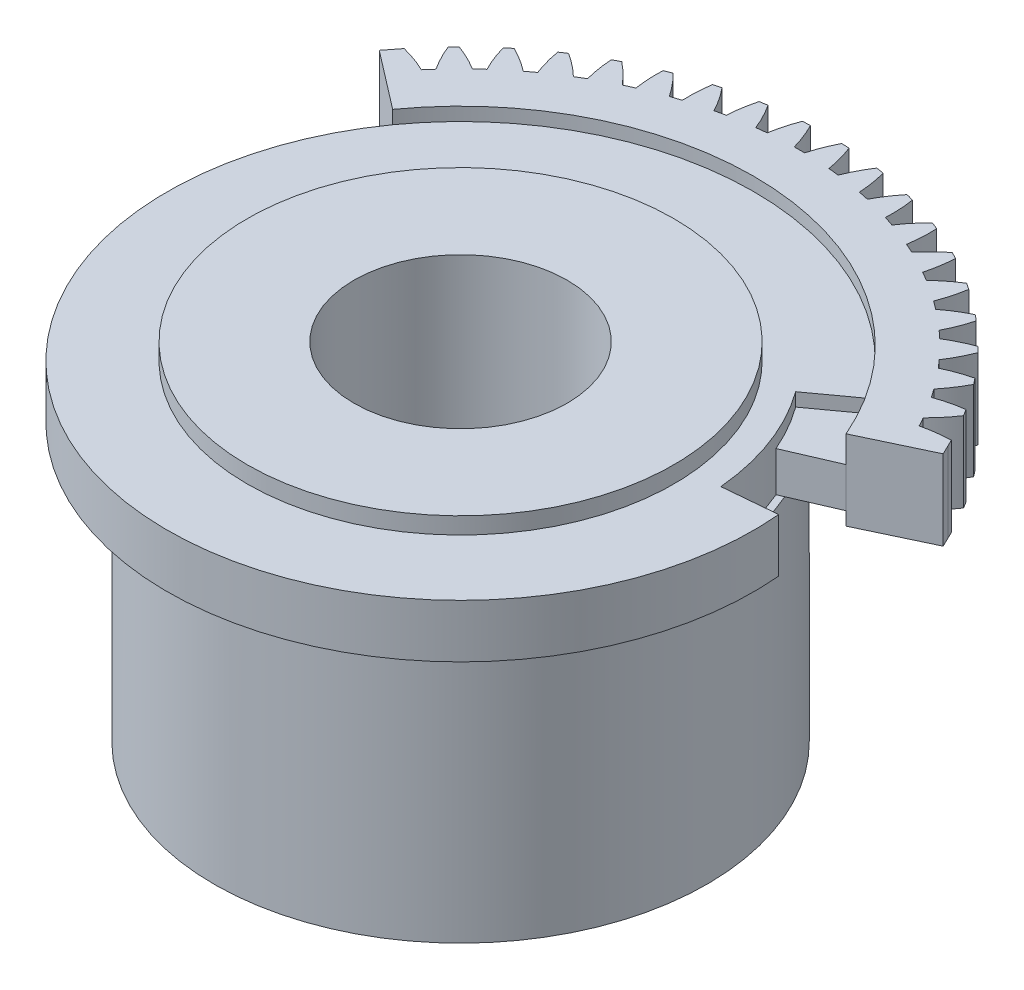
from build123d import *

# Parameters (mm, degrees)
BOSS_EXTRUDE1_DEPTH = 6
BOSS_EXTRUDE2_START = 1
SKETCH1_3_R         = 16
BOSS_EXTRUDE2_DEPTH = 4
CUT_EXTRUDE2_START  = 5
CUT_EXTRUDE2_DEPTH  = 1
SKETCH1_5_R         = 16
SKETCH1_5_R_2       = 8
BOSS_EXTRUDE3_DEPTH = 6.25
SKETCH2_R           = 18.5
BOSS_EXTRUDE4_DEPTH = 20.75
CUT_EXTRUDE3_START  = 6.25
SKETCH1_6_R         = 8
CUT_EXTRUDE3_DEPTH  = 13
SKETCH3_R           = 5
CUT_EXTRUDE4_DEPTH  = 11


with BuildPart() as part:
    # Sketch1 → Boss-Extrude1 (new body)
    with BuildSketch(Plane(origin=(0, 0, 0), x_dir=(1, 0, 0), z_dir=(0, 1, 0))):
        with BuildLine():
            ThreePointArc((17.805731394, 12.921142733), (19.115621979, 10.890041155), (20.194814379, 8.727512373))
            Line((20.194814379, 8.727512373), (25.139742278, 11.067703815))
            Line((25.139742278, 11.067703815), (24.811761788, 11.742187913))
            ThreePointArc((24.811761788, 11.742187913), (24.686117973, 12.004085947), (24.557709816, 12.264639767))
            ThreePointArc((24.557709816, 12.264639767), (23.484144419, 12.175944584), (22.425086919, 11.978950399))
            ThreePointArc((22.425086919, 11.978950399), (22.239976661, 12.319221327), (22.049703631, 12.656632481))
            ThreePointArc((22.049703631, 12.656632481), (22.778448625, 13.44994215), (23.423080118, 14.312994718))
            ThreePointArc((23.423080118, 14.312994718), (23.270310046, 14.560053928), (23.114934172, 14.805482708))
            ThreePointArc((23.114934172, 14.805482708), (22.056878458, 14.603176993), (21.02475993, 14.294727906))
            ThreePointArc((21.02475993, 14.294727906), (20.804529775, 14.613395117), (20.579470072, 14.928669986))
            ThreePointArc((20.579470072, 14.928669986), (21.21976293, 15.794946243), (21.769005591, 16.721629574))
            ThreePointArc((21.769005591, 16.721629574), (21.590840207, 16.95105068), (21.410257088, 17.178573614))
            ThreePointArc((21.410257088, 17.178573614), (20.379699251, 16.864949571), (19.386214008, 16.448540434))
            ThreePointArc((19.386214008, 16.448540434), (19.133359253, 16.741993301), (18.876062894, 17.031559695))
            ThreePointArc((18.876062894, 17.031559695), (19.420648841, 17.960987283), (19.868279532, 18.940801685))
            ThreePointArc((19.868279532, 18.940801685), (19.666737521, 19.149985255), (19.462993236, 19.357024417))
            ThreePointArc((19.462993236, 19.357024417), (18.471609908, 18.935635532), (17.528014536, 18.415984427))
            ThreePointArc((17.528014536, 18.415984427), (17.245400125, 18.680898012), (16.95878238, 18.941475027))
            ThreePointArc((16.95878238, 18.941475027), (17.401491042, 19.923523161), (17.742437927, 20.945366944))
            ThreePointArc((17.742437927, 20.945366944), (17.519802841, 21.131942845), (17.295205894, 21.316152399))
            ThreePointArc((17.295205894, 21.316152399), (16.354229843, 20.791773177), (15.471215656, 20.174767957))
            ThreePointArc((15.471215656, 20.174767957), (15.162043723, 20.408140683), (14.849352086, 20.636775878))
            ThreePointArc((14.849352086, 20.636775878), (15.185167395, 21.66031756), (15.41556741, 22.712612827))
            ThreePointArc((15.41556741, 22.712612827), (15.174361794, 22.874467079), (14.931456958, 23.033759856))
            ThreePointArc((14.931456958, 23.033759856), (14.05154982, 22.412331723), (13.23912172, 21.704963305))
            ThreePointArc((13.23912172, 21.704963305), (12.906895308, 21.904150965), (12.571672699, 22.098253812))
            ThreePointArc((12.571672699, 22.098253812), (12.796789734, 23.151691906), (12.914032356, 24.222515731))
            ThreePointArc((12.914032356, 24.222515731), (12.656989165, 24.35781446), (12.398528649, 24.49038561))
            ThreePointArc((12.398528649, 24.49038561), (11.589660123, 23.778949595), (10.857023245, 22.989232746))
            ThreePointArc((10.857023245, 22.989232746), (10.505506611, 23.151978465), (10.151551237, 23.309349701))
            ThreePointArc((10.151551237, 23.309349701), (10.263419333, 24.380748332), (10.266176154, 25.457967852))
            ThreePointArc((10.266176154, 25.457967852), (9.996207791, 25.565178071), (9.725120055, 25.66952551))
            ThreePointArc((9.725120055, 25.66952551), (8.996454945, 24.876142467), (8.351910358, 24.013024994))
            ThreePointArc((8.351910358, 24.013024994), (7.985086326, 24.137484798), (7.616408643, 24.256341344))
            ThreePointArc((7.616408643, 24.256341344), (7.613760289, 25.333561137), (7.502000074, 26.404971026))
            ThreePointArc((7.502000074, 26.404971026), (7.222165388, 26.482877999), (6.941521966, 26.557819428))
            ThreePointArc((6.941521966, 26.557819428), (6.301316338, 25.691478704), (5.752166989, 24.764740074))
            ThreePointArc((5.752166989, 24.764740074), (5.374191823, 24.849503783), (4.994969096, 24.928498947))
            ThreePointArc((4.994969096, 24.928498947), (4.877834298, 25.999334571), (4.652823336, 27.052795327))
            ThreePointArc((4.652823336, 27.052795327), (4.366292966, 27.100516337), (4.079273659, 27.145202641))
            ThreePointArc((4.079273659, 27.145202641), (3.5347813, 26.215720222), (3.087249271, 25.235860753))
            ThreePointArc((3.087249271, 25.235860753), (2.702405579, 25.279967961), (2.316934553, 25.318206696))
            ThreePointArc((2.316934553, 25.318206696), (2.086640496, 26.370525157), (1.750928251, 27.394100647))
            ThreePointArc((1.750928251, 27.394100647), (1.460948699, 27.411094996), (1.170805551, 27.425019861))
            ThreePointArc((1.170805551, 27.425019861), (0.728195776, 26.442927155), (0.387351784, 25.421049046))
            ThreePointArc((0.387351784, 25.421049046), (0, 25.424), (-0.387351784, 25.421049046))
            ThreePointArc((-0.387351784, 25.421049046), (-0.728195776, 26.442927155), (-1.170805551, 27.425019861))
            ThreePointArc((-1.170805551, 27.425019861), (-1.460948699, 27.411094996), (-1.750928251, 27.394100647))
            ThreePointArc((-1.750928251, 27.394100647), (-2.086640496, 26.370525157), (-2.316934553, 25.318206696))
            ThreePointArc((-2.316934553, 25.318206696), (-2.702405579, 25.279967961), (-3.087249271, 25.235860753))
            ThreePointArc((-3.087249271, 25.235860753), (-3.5347813, 26.215720222), (-4.079273659, 27.145202641))
            ThreePointArc((-4.079273659, 27.145202641), (-4.366292966, 27.100516337), (-4.652823336, 27.052795327))
            ThreePointArc((-4.652823336, 27.052795327), (-4.877834298, 25.999334571), (-4.994969096, 24.928498947))
            ThreePointArc((-4.994969096, 24.928498947), (-5.374191823, 24.849503783), (-5.752166989, 24.764740074))
            ThreePointArc((-5.752166989, 24.764740074), (-6.301316338, 25.691478704), (-6.941521966, 26.557819428))
            ThreePointArc((-6.941521966, 26.557819428), (-7.222165388, 26.482877999), (-7.502000074, 26.404971026))
            ThreePointArc((-7.502000074, 26.404971026), (-7.613760289, 25.333561137), (-7.616408643, 24.256341344))
            ThreePointArc((-7.616408643, 24.256341344), (-7.985086326, 24.137484798), (-8.351910358, 24.013024994))
            ThreePointArc((-8.351910358, 24.013024994), (-8.996454945, 24.876142467), (-9.725120055, 25.66952551))
            ThreePointArc((-9.725120055, 25.66952551), (-9.996207791, 25.565178071), (-10.266176154, 25.457967852))
            ThreePointArc((-10.266176154, 25.457967852), (-10.263419333, 24.380748332), (-10.151551237, 23.309349701))
            ThreePointArc((-10.151551237, 23.309349701), (-10.505506611, 23.151978465), (-10.857023245, 22.989232746))
            ThreePointArc((-10.857023245, 22.989232746), (-11.589660123, 23.778949595), (-12.398528649, 24.49038561))
            ThreePointArc((-12.398528649, 24.49038561), (-12.656989165, 24.35781446), (-12.914032356, 24.222515731))
            ThreePointArc((-12.914032356, 24.222515731), (-12.796789734, 23.151691906), (-12.571672699, 22.098253812))
            ThreePointArc((-12.571672699, 22.098253812), (-12.906895308, 21.904150965), (-13.23912172, 21.704963305))
            ThreePointArc((-13.23912172, 21.704963305), (-14.05154982, 22.412331723), (-14.931456958, 23.033759856))
            ThreePointArc((-14.931456958, 23.033759856), (-15.174361794, 22.874467079), (-15.41556741, 22.712612827))
            ThreePointArc((-15.41556741, 22.712612827), (-15.185167395, 21.66031756), (-14.849352086, 20.636775878))
            ThreePointArc((-14.849352086, 20.636775878), (-15.162043723, 20.408140683), (-15.471215656, 20.174767957))
            ThreePointArc((-15.471215656, 20.174767957), (-16.354229843, 20.791773177), (-17.295205894, 21.316152399))
            ThreePointArc((-17.295205894, 21.316152399), (-17.519802841, 21.131942845), (-17.742437927, 20.945366944))
            ThreePointArc((-17.742437927, 20.945366944), (-17.401491042, 19.923523161), (-16.95878238, 18.941475027))
            ThreePointArc((-16.95878238, 18.941475027), (-17.245400125, 18.680898012), (-17.528014536, 18.415984427))
            ThreePointArc((-17.528014536, 18.415984427), (-18.471609908, 18.935635532), (-19.462993236, 19.357024417))
            ThreePointArc((-19.462993236, 19.357024417), (-19.666737521, 19.149985255), (-19.868279532, 18.940801685))
            ThreePointArc((-19.868279532, 18.940801685), (-19.420648841, 17.960987283), (-18.876062894, 17.031559695))
            ThreePointArc((-18.876062894, 17.031559695), (-19.133359253, 16.741993301), (-19.386214008, 16.448540434))
            ThreePointArc((-19.386214008, 16.448540434), (-20.379699251, 16.864949571), (-21.410257088, 17.178573614))
            ThreePointArc((-21.410257088, 17.178573614), (-21.590840207, 16.95105068), (-21.769005591, 16.721629574))
            Line((-21.769005591, 16.721629574), (-22.232149052, 16.131715907))
            Line((-22.232149052, 16.131715907), (-17.893635567, 12.799133025))
            ThreePointArc((-17.893635567, 12.799133025), (-0.07518895, 21.999871514), (17.805731394, 12.921142733))
        make_face()
    extrude(amount=BOSS_EXTRUDE1_DEPTH)

    # Sketch1_3 → Boss-Extrude2 (add)
    with BuildSketch(Plane(origin=(0, 0, 0), x_dir=(1, 0, 0), z_dir=(0, 1, 0)).offset(BOSS_EXTRUDE2_START)):
        with BuildLine():
            ThreePointArc((17.928788602, 1.599543458), (17.447292969, 4.426281516), (16.523029946, 7.140691941))
            ThreePointArc((16.523029946, 7.140691941), (15.640054347, 8.910033672), (14.568325686, 10.571844055))
            Line((14.568325686, 10.571844055), (15.377677113, 11.159168724))
            Line((15.377677113, 11.159168724), (17.805731394, 12.921142733))
            ThreePointArc((17.805731394, 12.921142733), (-0.07518895, 21.999871514), (-17.893635567, 12.799133025))
            ThreePointArc((-17.893635567, 12.799133025), (-5.782522672, -21.226455935), (21.912963847, 1.954997559))
            Line((21.912963847, 1.954997559), (17.928788602, 1.599543458))
        make_face()
        Circle(SKETCH1_3_R, mode=Mode.SUBTRACT)
        with BuildLine():
            ThreePointArc((14.568325686, 10.571844055), (15.640054347, 8.910033672), (16.523029946, 7.140691941))
            Line((16.523029946, 7.140691941), (20.194814379, 8.727512373))
            ThreePointArc((20.194814379, 8.727512373), (19.115621979, 10.890041155), (17.805731394, 12.921142733))
            Line((17.805731394, 12.921142733), (15.377677113, 11.159168724))
            Line((15.377677113, 11.159168724), (14.568325686, 10.571844055))
        make_face()
    extrude(amount=BOSS_EXTRUDE2_DEPTH)

    # Sketch1_4 → Cut-Extrude2 (cut)
    with BuildSketch(Plane(origin=(0, 0, 0), x_dir=(1, 0, 0), z_dir=(0, 1, 0)).offset(CUT_EXTRUDE2_START)):
        with BuildLine():
            ThreePointArc((14.568325686, 10.571844055), (15.640054347, 8.910033672), (16.523029946, 7.140691941))
            Line((16.523029946, 7.140691941), (20.194814379, 8.727512373))
            ThreePointArc((20.194814379, 8.727512373), (19.115621979, 10.890041155), (17.805731394, 12.921142733))
            Line((17.805731394, 12.921142733), (15.377677113, 11.159168724))
            Line((15.377677113, 11.159168724), (14.568325686, 10.571844055))
        make_face()
    extrude(amount=-CUT_EXTRUDE2_DEPTH, mode=Mode.SUBTRACT)

    # Sketch1_5 → Boss-Extrude3 (add)
    with BuildSketch(Plane(origin=(0, 0, 0), x_dir=(1, 0, 0), z_dir=(0, 1, 0))):
        Circle(SKETCH1_5_R)
        Circle(SKETCH1_5_R_2, mode=Mode.SUBTRACT)
    extrude(amount=BOSS_EXTRUDE3_DEPTH)

    # Sketch2 → Boss-Extrude4 (add)
    with BuildSketch(Plane.XZ.offset(-1)):
        Circle(SKETCH2_R)
    extrude(amount=BOSS_EXTRUDE4_DEPTH)

    # Sketch1_6 → Cut-Extrude3 (cut)
    with BuildSketch(Plane(origin=(0, 0, 0), x_dir=(1, 0, 0), z_dir=(0, 1, 0)).offset(CUT_EXTRUDE3_START)):
        Circle(SKETCH1_6_R)
    extrude(amount=-CUT_EXTRUDE3_DEPTH, mode=Mode.SUBTRACT)

    # Sketch3 → Cut-Extrude4 (cut)
    with BuildSketch(Plane.XZ.offset(19.75)):
        Circle(SKETCH3_R)
    extrude(amount=-CUT_EXTRUDE4_DEPTH, mode=Mode.SUBTRACT)


solid = part.part
